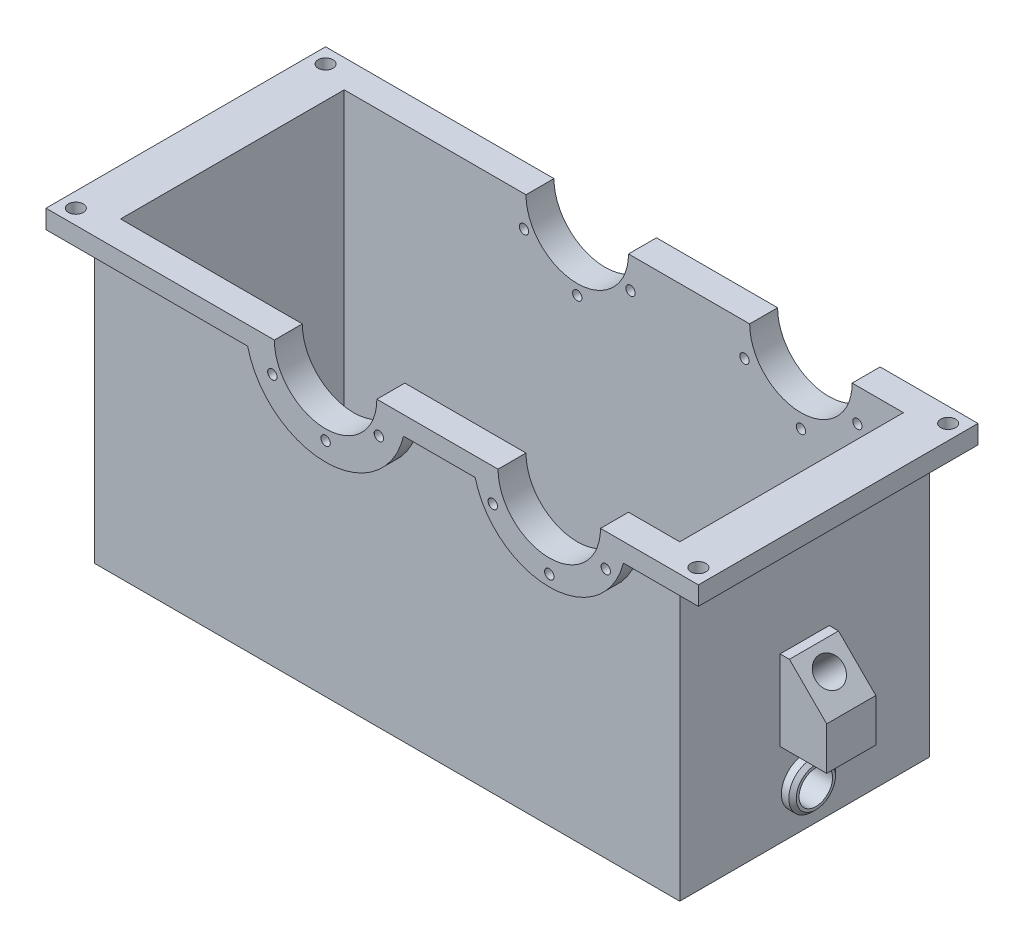
from build123d import *

# Parameters (mm, degrees)
SKETCH1_W                       = 314
SKETCH1_H                       = 134
BOSS_EXTRUDE1_DEPTH             = 160
SKETCH2_W                       = 350
SKETCH2_H                       = 150
BOSS_EXTRUDE3_DEPTH             = 10
SKETCH3_R                       = 41
BOSS_EXTRUDE5_DEPTH             = 150
F_5_0MM_DOWEL_HOLE1_D           = 5
F_5_0MM_DOWEL_HOLE1_CSINK_D     = 5.05
F_5_0MM_DOWEL_HOLE1_CSINK_ANGLE = 100
CIRPATTERN1_COUNT               = 6
SKETCH3_3_R                     = 27.5
CUT_EXTRUDE1_DEPTH              = 151
SKETCH6_R                       = 43
BOSS_EXTRUDE6_DEPTH             = 150
SKETCH6_3_R                     = 27.5
CUT_EXTRUDE2_DEPTH              = 151
F_5_0MM_DOWEL_HOLE2_D           = 5
F_5_0MM_DOWEL_HOLE2_CSINK_D     = 5.05
F_5_0MM_DOWEL_HOLE2_CSINK_ANGLE = 100
CIRPATTERN2_COUNT               = 6
MIRROR1_COPY_1_D                = 5
MIRROR1_COPY_1_CSINK_D          = 5.05
MIRROR1_COPY_1_CSINK_ANGLE      = 100
MIRROR1_COPY_2_D                = 5
MIRROR1_COPY_2_CSINK_D          = 5.05
MIRROR1_COPY_2_CSINK_ANGLE      = 100
MIRROR1_COPY_3_D                = 5
MIRROR1_COPY_3_CSINK_D          = 5.05
MIRROR1_COPY_3_CSINK_ANGLE      = 100
MIRROR1_COPY_4_D                = 5
MIRROR1_COPY_4_CSINK_D          = 5.05
MIRROR1_COPY_4_CSINK_ANGLE      = 100
MIRROR1_COPY_5_D                = 5
MIRROR1_COPY_5_CSINK_D          = 5.05
MIRROR1_COPY_5_CSINK_ANGLE      = 100
MIRROR2_COPY_1_D                = 5
MIRROR2_COPY_1_CSINK_D          = 5.05
MIRROR2_COPY_1_CSINK_ANGLE      = 100
MIRROR2_COPY_2_D                = 5
MIRROR2_COPY_2_CSINK_D          = 5.05
MIRROR2_COPY_2_CSINK_ANGLE      = 100
MIRROR2_COPY_3_D                = 5
MIRROR2_COPY_3_CSINK_D          = 5.05
MIRROR2_COPY_3_CSINK_ANGLE      = 100
MIRROR2_COPY_4_D                = 5
MIRROR2_COPY_4_CSINK_D          = 5.05
MIRROR2_COPY_4_CSINK_ANGLE      = 100
MIRROR2_COPY_5_D                = 5
MIRROR2_COPY_5_CSINK_D          = 5.05
MIRROR2_COPY_5_CSINK_ANGLE      = 100
SKETCH9_R                       = 12.5
BOSS_EXTRUDE7_DEPTH             = 6
CUT_EXTRUDE3_START              = 6
SKETCH9_3_R                     = 9
CUT_EXTRUDE3_DEPTH              = 30
CHAMFER1_SIZE                   = 2
SKETCH10_W                      = 26.35
SKETCH10_H                      = 43
BOSS_EXTRUDE8_DEPTH             = 25
CUT_EXTRUDE4_REACH              = 90.175
SKETCH12_R                      = 7.5
CUT_EXTRUDE5_DEPTH              = 50
CUT_EXTRUDE6_START              = -161
SKETCH13_R                      = 4
CUT_EXTRUDE6_DEPTH              = 205
MIRROR5_START                   = -161
MIRROR5_COPY_1_SKETCH_R         = 4
MIRROR5_COPY_1_DEPTH            = 205
MIRROR5_COPY_2_SKETCH_R         = 4
MIRROR5_COPY_2_DEPTH            = 205
SKETCH14_W                      = 364.166364604
SKETCH14_H                      = 92.820269588
CUT_EXTRUDE7_DEPTH              = 151
SKETCH15_W                      = 300
SKETCH15_H                      = 120
CUT_EXTRUDE9_DEPTH              = 150


with BuildPart() as part:
    # Sketch1 → Boss-Extrude1 (new body)
    with BuildSketch(Plane(origin=(0, 0, 0), x_dir=(1, 0, 0), z_dir=(0, 1, 0))):
        Rectangle(SKETCH1_W, SKETCH1_H)
    extrude(amount=BOSS_EXTRUDE1_DEPTH)

    # Sketch2 → Boss-Extrude3 (add)
    with BuildSketch(Plane(origin=(0, 160, 0), x_dir=(1, 0, 0), z_dir=(0, 1, 0))):
        Rectangle(SKETCH2_W, SKETCH2_H)
    extrude(amount=-BOSS_EXTRUDE3_DEPTH)

    # Sketch3 → Boss-Extrude5 (add, through all)
    with BuildSketch(Plane.XY.offset(75)):
        with Locations((95, 160)):
            Circle(SKETCH3_R)
    extrude(amount=-BOSS_EXTRUDE5_DEPTH)

    # Ø5.0mm Dowel Hole1 (through all)
    with Locations(Plane.XY.offset(75)):
        with Locations((95, 195)):
            f_5_0mm_dowel_hole1 = CounterSinkHole(F_5_0MM_DOWEL_HOLE1_D / 2, F_5_0MM_DOWEL_HOLE1_CSINK_D / 2, counter_sink_angle=F_5_0MM_DOWEL_HOLE1_CSINK_ANGLE)

    # CirPattern1: Ø5.0mm Dowel Hole1 ×6 about axis
    cirpattern1_axis = Axis((95, 160, 0), (0, 0, 1))
    for i in range(1, CIRPATTERN1_COUNT):
        add(f_5_0mm_dowel_hole1.rotate(cirpattern1_axis, i * 360 / CIRPATTERN1_COUNT), mode=Mode.SUBTRACT)

    # Sketch3_3 → Cut-Extrude1 (cut, through all)
    with BuildSketch(Plane.XY.offset(75)):
        with Locations((95, 160)):
            Circle(SKETCH3_3_R)
    extrude(amount=-CUT_EXTRUDE1_DEPTH, mode=Mode.SUBTRACT)

    # Sketch6 → Boss-Extrude6 (add, through all)
    with BuildSketch(Plane.XY.offset(75)):
        with Locations((-25, 160)):
            Circle(SKETCH6_R)
    extrude(amount=-BOSS_EXTRUDE6_DEPTH)

    # Sketch6_3 → Cut-Extrude2 (cut, through all)
    with BuildSketch(Plane.XY.offset(75)):
        with Locations((-25, 160)):
            Circle(SKETCH6_3_R)
    extrude(amount=-CUT_EXTRUDE2_DEPTH, mode=Mode.SUBTRACT)

    # Ø5.0mm Dowel Hole2 (through all)
    with Locations(Plane.XY.offset(75)):
        with Locations((-25, 193)):
            f_5_0mm_dowel_hole2 = CounterSinkHole(F_5_0MM_DOWEL_HOLE2_D / 2, F_5_0MM_DOWEL_HOLE2_CSINK_D / 2, counter_sink_angle=F_5_0MM_DOWEL_HOLE2_CSINK_ANGLE)

    # CirPattern2: Ø5.0mm Dowel Hole2 ×6 about axis
    cirpattern2_axis = Axis((-25, 160, 0), (0, 0, 1))
    for i in range(1, CIRPATTERN2_COUNT):
        add(f_5_0mm_dowel_hole2.rotate(cirpattern2_axis, i * 360 / CIRPATTERN2_COUNT), mode=Mode.SUBTRACT)

    # Mirror1: Ø5.0mm Dowel Hole2 across plane
    add(f_5_0mm_dowel_hole2.mirror(Plane.XY), mode=Mode.SUBTRACT)

    # Mirror1 copy 1 (through all)
    with Locations(Plane(origin=(126.064064606, 101.650635095, -75), x_dir=(0.5, 0.866025404, 0), z_dir=(0, 0, -1))):
        with Locations((-25, -193)):
            CounterSinkHole(MIRROR1_COPY_1_D / 2, MIRROR1_COPY_1_CSINK_D / 2, counter_sink_angle=MIRROR1_COPY_1_CSINK_ANGLE)

    # Mirror1 copy 2 (through all)
    with Locations(Plane(origin=(101.064064606, 261.650635095, -75), x_dir=(-0.5, 0.866025404, 0), z_dir=(0, 0, -1))):
        with Locations((-25, -193)):
            CounterSinkHole(MIRROR1_COPY_2_D / 2, MIRROR1_COPY_2_CSINK_D / 2, counter_sink_angle=MIRROR1_COPY_2_CSINK_ANGLE)

    # Mirror1 copy 3 (through all)
    with Locations(Plane(origin=(-50, 320, -75), x_dir=(-1, 0, 0), z_dir=(0, 0, -1))):
        with Locations((-25, -193)):
            CounterSinkHole(MIRROR1_COPY_3_D / 2, MIRROR1_COPY_3_CSINK_D / 2, counter_sink_angle=MIRROR1_COPY_3_CSINK_ANGLE)

    # Mirror1 copy 4 (through all)
    with Locations(Plane(origin=(-176.064064606, 218.349364905, -75), x_dir=(-0.5, -0.866025404, 0), z_dir=(0, 0, -1))):
        with Locations((-25, -193)):
            CounterSinkHole(MIRROR1_COPY_4_D / 2, MIRROR1_COPY_4_CSINK_D / 2, counter_sink_angle=MIRROR1_COPY_4_CSINK_ANGLE)

    # Mirror1 copy 5 (through all)
    with Locations(Plane(origin=(-151.064064606, 58.349364905, -75), x_dir=(0.5, -0.866025404, 0), z_dir=(0, 0, -1))):
        with Locations((-25, -193)):
            CounterSinkHole(MIRROR1_COPY_5_D / 2, MIRROR1_COPY_5_CSINK_D / 2, counter_sink_angle=MIRROR1_COPY_5_CSINK_ANGLE)

    # Mirror2: Ø5.0mm Dowel Hole1 across plane
    add(f_5_0mm_dowel_hole1.mirror(Plane.XY), mode=Mode.SUBTRACT)

    # Mirror2 copy 1 (through all)
    with Locations(Plane(origin=(186.064064606, -2.27241336, -75), x_dir=(0.5, 0.866025404, 0), z_dir=(0, 0, -1))):
        with Locations((95, -195)):
            CounterSinkHole(MIRROR2_COPY_1_D / 2, MIRROR2_COPY_1_CSINK_D / 2, counter_sink_angle=MIRROR2_COPY_1_CSINK_ANGLE)

    # Mirror2 copy 2 (through all)
    with Locations(Plane(origin=(281.064064606, 157.72758664, -75), x_dir=(-0.5, 0.866025404, 0), z_dir=(0, 0, -1))):
        with Locations((95, -195)):
            CounterSinkHole(MIRROR2_COPY_2_D / 2, MIRROR2_COPY_2_CSINK_D / 2, counter_sink_angle=MIRROR2_COPY_2_CSINK_ANGLE)

    # Mirror2 copy 3 (through all)
    with Locations(Plane(origin=(190, 320, -75), x_dir=(-1, 0, 0), z_dir=(0, 0, -1))):
        with Locations((95, -195)):
            CounterSinkHole(MIRROR2_COPY_3_D / 2, MIRROR2_COPY_3_CSINK_D / 2, counter_sink_angle=MIRROR2_COPY_3_CSINK_ANGLE)

    # Mirror2 copy 4 (through all)
    with Locations(Plane(origin=(3.935935394, 322.27241336, -75), x_dir=(-0.5, -0.866025404, 0), z_dir=(0, 0, -1))):
        with Locations((95, -195)):
            CounterSinkHole(MIRROR2_COPY_4_D / 2, MIRROR2_COPY_4_CSINK_D / 2, counter_sink_angle=MIRROR2_COPY_4_CSINK_ANGLE)

    # Mirror2 copy 5 (through all)
    with Locations(Plane(origin=(-91.064064606, 162.27241336, -75), x_dir=(0.5, -0.866025404, 0), z_dir=(0, 0, -1))):
        with Locations((95, -195)):
            CounterSinkHole(MIRROR2_COPY_5_D / 2, MIRROR2_COPY_5_CSINK_D / 2, counter_sink_angle=MIRROR2_COPY_5_CSINK_ANGLE)

    # Sketch9 → Boss-Extrude7 (add)
    with BuildSketch(Plane(origin=(157, 0, 0), x_dir=(0, 0, -1), z_dir=(1, 0, 0))):
        with Locations((0, 22.5)):
            Circle(SKETCH9_R)
    extrude(amount=BOSS_EXTRUDE7_DEPTH)

    # Sketch9_3 → Cut-Extrude3 (cut)
    with BuildSketch(Plane(origin=(157, 0, 0), x_dir=(0, 0, -1), z_dir=(1, 0, 0)).offset(CUT_EXTRUDE3_START)):
        with Locations((0, 22.5)):
            Circle(SKETCH9_3_R)
    extrude(amount=-CUT_EXTRUDE3_DEPTH, mode=Mode.SUBTRACT)

    # Chamfer1
    chamfer1_edges = [part.edges().sort_by_distance(p)[0] for p in [
        (163, 22.5, 12.5),
    ]]
    chamfer(chamfer1_edges, length=CHAMFER1_SIZE)

    # Sketch10 → Boss-Extrude8 (add)
    with BuildSketch(Plane(origin=(157, 0, 0), x_dir=(0, 0, -1), z_dir=(1, 0, 0))):
        with Locations((0, 66.5)):
            Rectangle(SKETCH10_W, SKETCH10_H)
    extrude(amount=BOSS_EXTRUDE8_DEPTH)

    # Sketch11 → Cut-Extrude4 (cut, up to next)
    with BuildSketch(Plane(origin=(0, 0, -13.175), x_dir=(-1, 0, 0), z_dir=(0, 0, -1)), mode=Mode.PRIVATE) as cut_extrude4_sk1:
        Polygon((-162, 88), (-182, 68), (-200.649139224, 72.819299993), (-183.741650688, 106.337654458), align=None)
    cut_extrude4_tool1 = extrude(cut_extrude4_sk1.sketch, amount=-CUT_EXTRUDE4_REACH, mode=Mode.PRIVATE) & part.part
    add(cut_extrude4_tool1.solids().sort_by_distance((181.949584, 85.075168, -13.175))[0], mode=Mode.SUBTRACT)

    # Sketch12 → Cut-Extrude5 (cut)
    with BuildSketch(Plane(origin=(125, 125, 0), x_dir=(0, 0, -1), z_dir=(0.707106781, 0.707106781, 0))):
        with Locations((0, -63.993163697)):
            Circle(SKETCH12_R)
    extrude(amount=-CUT_EXTRUDE5_DEPTH, mode=Mode.SUBTRACT)

    # Sketch13 → Cut-Extrude6 (cut)
    with BuildSketch(Plane(origin=(0, 160, 0), x_dir=(1, 0, 0), z_dir=(0, 1, 0)).offset(CUT_EXTRUDE6_START)):
        with Locations((-167, 67)):
            Circle(SKETCH13_R)
    cut_extrude6 = extrude(amount=CUT_EXTRUDE6_DEPTH, mode=Mode.SUBTRACT)

    # Mirror3: Cut-Extrude6 across plane
    add(cut_extrude6.mirror(Plane(origin=(0, 0, 0), x_dir=(0, 0, 1), z_dir=(1, 0, 0))), mode=Mode.SUBTRACT)

    # Mirror4: Cut-Extrude6 across plane
    add(cut_extrude6.mirror(Plane.XY), mode=Mode.SUBTRACT)

    # Mirror5 copy 1 sketch → Mirror5 copy 1 (cut)
    with BuildSketch(Plane(origin=(0, 160, 0), x_dir=(-1, 0, 0), z_dir=(0, 1, 0)).offset(MIRROR5_START)):
        with Locations((-167, 67)):
            Circle(MIRROR5_COPY_1_SKETCH_R)
    extrude(amount=MIRROR5_COPY_1_DEPTH, mode=Mode.SUBTRACT)

    # Mirror5 copy 2 sketch → Mirror5 copy 2 (cut)
    with BuildSketch(Plane(origin=(0, 160, 0), x_dir=(1, 0, 0), z_dir=(0, 1, 0)).offset(MIRROR5_START)):
        with Locations((-167, -67)):
            Circle(MIRROR5_COPY_2_SKETCH_R)
    extrude(amount=MIRROR5_COPY_2_DEPTH, mode=Mode.SUBTRACT)

    # Sketch14 → Cut-Extrude7 (cut, through all)
    with BuildSketch(Plane.XY.offset(75)):
        with Locations((7.083182302, 206.410134794)):
            Rectangle(SKETCH14_W, SKETCH14_H)
    extrude(amount=-CUT_EXTRUDE7_DEPTH, mode=Mode.SUBTRACT)

    # Sketch15 → Cut-Extrude9 (cut)
    with BuildSketch(Plane(origin=(0, 160, 0), x_dir=(1, 0, 0), z_dir=(0, 1, 0))):
        Rectangle(SKETCH15_W, SKETCH15_H)
    extrude(amount=-CUT_EXTRUDE9_DEPTH, mode=Mode.SUBTRACT)


solid = part.part
